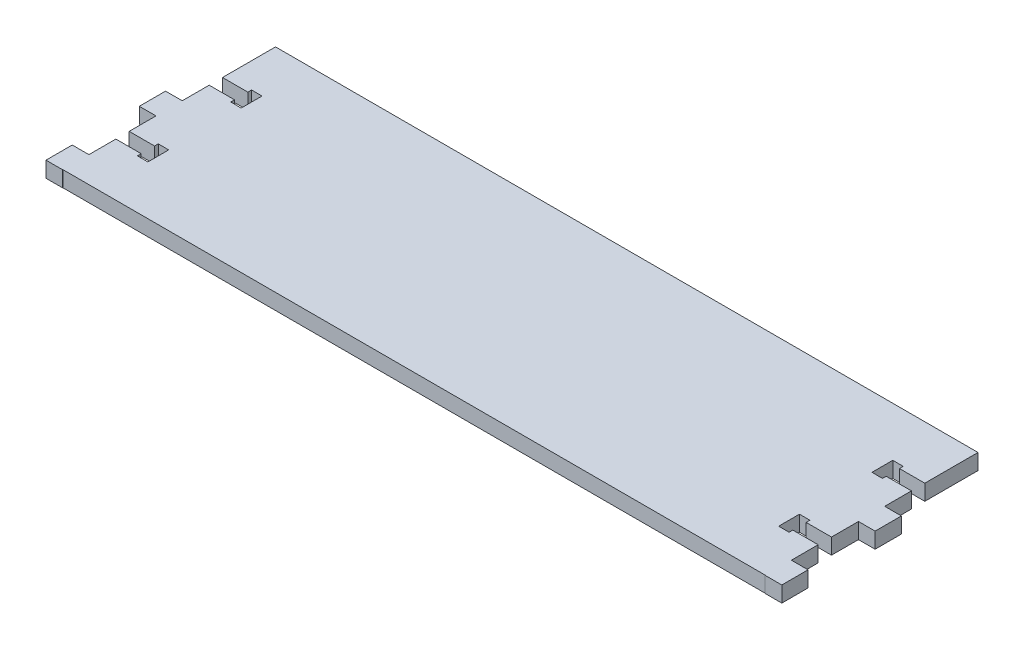
from build123d import *

# Parameters (mm, degrees)
SKETCH1_W      = 6.35
SKETCH1_H      = 10
EXTRUDE1_DEPTH = 5.9944


with BuildPart() as part:
    # Sketch1 → Extrude1 (new body)
    with BuildSketch(Plane(origin=(0, 0, 0), x_dir=(1, 0, 0), z_dir=(0, 1, 0))):
        with Locations((-43.270242604, 14.657356551)):
            Rectangle(SKETCH1_W, SKETCH1_H)
        Polygon((227.620757396, 55.217356551), (-40.095242604, 55.217356551), (-40.095242604, 45.217356551), (-40.095242604, 35.01384638), (-30.443242604, 35.01384638), (-30.443242604, 36.44259638), (-26.443242604, 36.406106551), (-26.443242604, 28.468606551), (-30.443242604, 28.50509638), (-30.443242604, 29.93384638), (-40.095242604, 29.93384638), (-40.095242604, 19.657356551), (-40.095242604, 9.657356551), (-40.095242604, -0.54615362), (-30.443242604, -0.54615362), (-30.443242604, 0.88259638), (-26.443242604, 0.846106551), (-26.443242604, -7.091393449), (-30.443242604, -7.05490362), (-30.443242604, -5.62615362), (-40.095242604, -5.62615362), (-40.095242604, -15.902643449), (-40.095242604, -25.808643449), (227.620757396, -25.808643449), (227.620757396, -15.902643449), (227.620757396, -5.699133278), (217.968757396, -5.699133278), (217.968757396, -7.127883278), (213.968757396, -7.091393449), (213.968757396, 0.846106551), (217.968757396, 0.809616722), (217.968757396, -0.619133278), (227.620757396, -0.619133278), (227.620757396, 9.657356551), (227.620757396, 19.657356551), (227.620757396, 29.860866722), (217.968757396, 29.860866722), (217.968757396, 28.432116722), (213.968757396, 28.468606551), (213.968757396, 36.406106551), (217.968757396, 36.369616722), (217.968757396, 34.940866722), (227.620757396, 34.940866722), (227.620757396, 45.217356551), align=None)
        Polygon((-40.095242604, -25.808643449), (-40.095242604, -15.902643449), (-46.445242604, -15.902643449), (-46.445242604, -25.902643449), (-40.095242604, -25.902643449), align=None)
        Polygon((233.970757396, -15.902643449), (227.620757396, -15.902643449), (227.620757396, -25.808643449), (227.620757396, -25.902643449), (233.970757396, -25.902643449), align=None)
        with Locations((230.795757396, 14.657356551)):
            Rectangle(SKETCH1_W, SKETCH1_H)
    extrude(amount=EXTRUDE1_DEPTH)


solid = part.part
